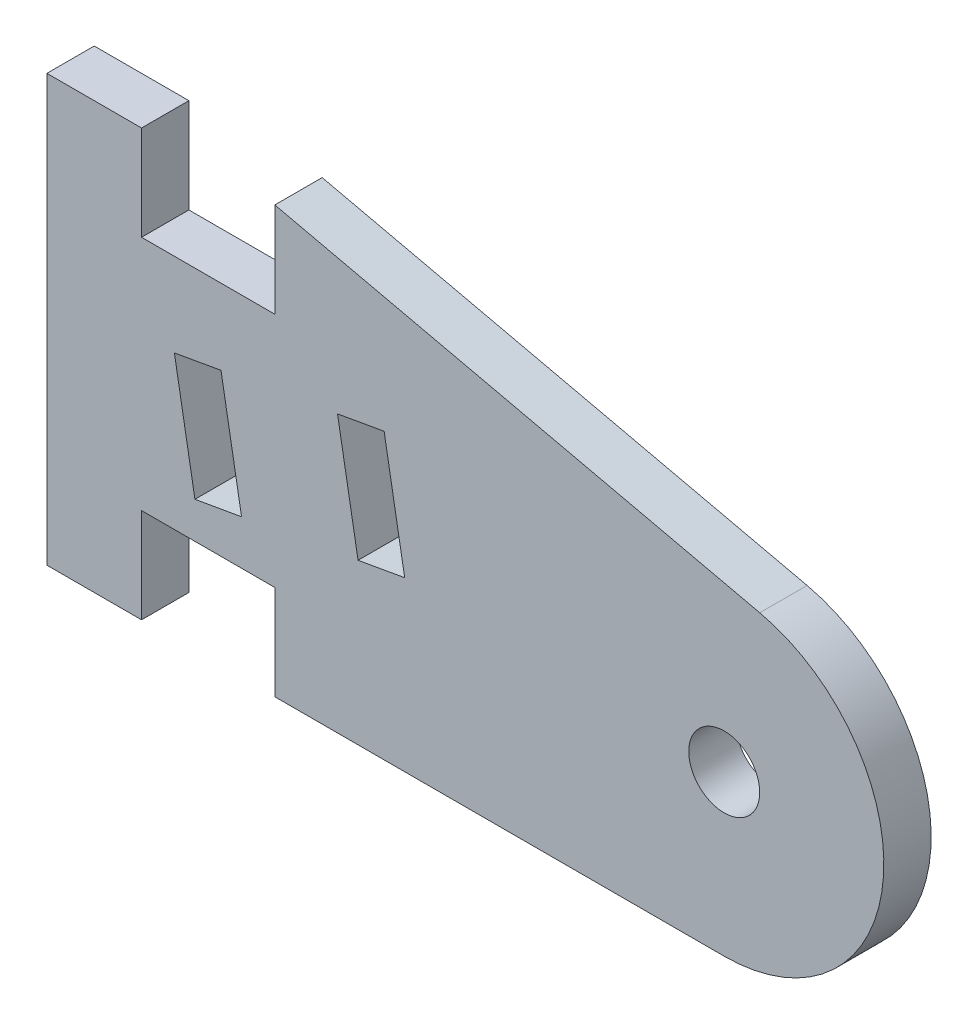
from build123d import *

# Parameters (mm, degrees)
SKETCH1_R           = 1.5
BOSS_EXTRUDE1_DEPTH = 2


with BuildPart() as part:
    # Sketch1 → Boss-Extrude1 (new body)
    with BuildSketch(Plane.XY):
        with BuildLine():
            Line((0, 0), (0, 18.000341084))
            Line((0, 18.000341084), (4, 18.000341084))
            Line((4, 18.000341084), (4, 14.000341084))
            Line((4, 14.000341084), (9.631516349, 14.000341084))
            Line((9.631516349, 14.000341084), (9.631516349, 18.000341084))
            Line((9.631516349, 18.000341084), (30.123176491, 13.320805491))
            ThreePointArc((30.123176491, 13.320805491), (35.324106187, 5.989458303), (28.621516349, 0))
            Line((28.621516349, 0), (9.631516349, 0))
            Line((9.631516349, 0), (9.631516349, 4))
            Line((9.631516349, 4), (4, 4))
            Line((4, 4), (4, 0))
            Line((4, 0), (0, 0))
        make_face()
        with Locations((28.621516349, 6.745044143)):
            Circle(SKETCH1_R, mode=Mode.SUBTRACT)
        Polygon((14.250450019, 12.02557168), (12.280834513, 11.678275325), (13.149075402, 6.75423656), (15.118690908, 7.101532915), align=None, mode=Mode.SUBTRACT)
        Polygon((7.356795748, 10.810034437), (8.225036637, 5.885995672), (6.255421131, 5.538699316), (5.387180242, 10.462738081), align=None, mode=Mode.SUBTRACT)
    extrude(amount=BOSS_EXTRUDE1_DEPTH)


solid = part.part
